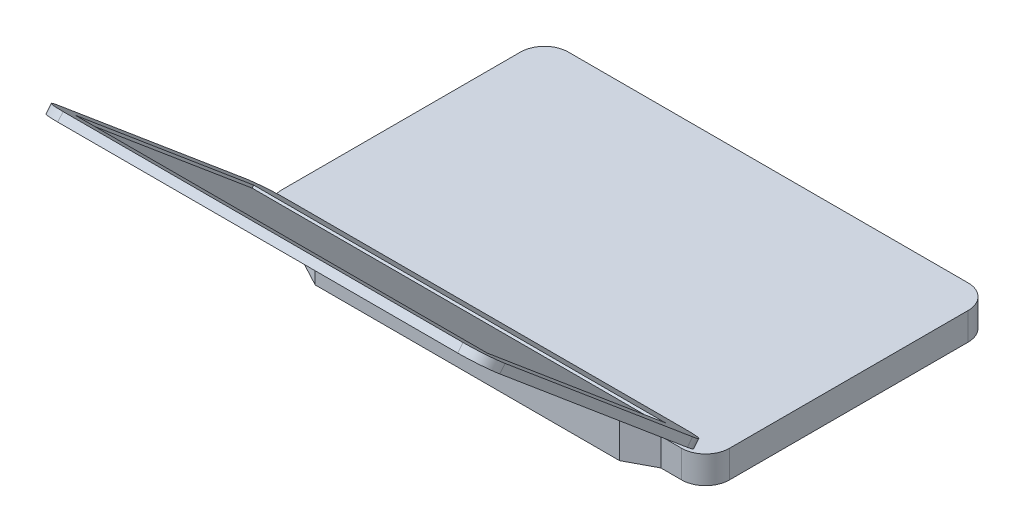
from build123d import *

# Parameters (mm, degrees)
SKETCH1_W           = 375
SKETCH1_H           = 240
BOSS_EXTRUDE1_DEPTH = 23
BOSS_EXTRUDE2_DEPTH = 34
CUT_EXTRUDE1_DEPTH  = 376
SKETCH5_W           = 375
SKETCH5_H           = 245
BOSS_EXTRUDE3_DEPTH = 7
SKETCH6_W           = 345
SKETCH6_H           = 195
CUT_EXTRUDE2_DEPTH  = 2
FILLET1_R           = 20


with BuildPart() as part:
    # Sketch1 → Boss-Extrude1 (new body)
    with BuildSketch(Plane(origin=(0, 0, 0), x_dir=(1, 0, 0), z_dir=(0, 1, 0))):
        Rectangle(SKETCH1_W, SKETCH1_H)
    extrude(amount=BOSS_EXTRUDE1_DEPTH)

    # Sketch3 → Boss-Extrude2 (add)
    with BuildSketch(Plane.XZ):
        Polygon((-150, 120), (-127.5, 132), (127.5, 132), (150, 120), align=None)
    extrude(amount=-BOSS_EXTRUDE2_DEPTH)

    # Sketch4 → Cut-Extrude1 (cut, through all)
    with BuildSketch(Plane.ZY.offset(187.5)):
        Polygon((120, 28.5), (126.554644759, 34), (120, 34), align=None)
    extrude(amount=-CUT_EXTRUDE1_DEPTH, mode=Mode.SUBTRACT)

    # Sketch5 → Boss-Extrude3 (add)
    with BuildSketch(Plane(origin=(0, -42.363978649, 35.54759886), x_dir=(-1, 0, 0), z_dir=(0, 0.766044443, -0.64278761))):
        with Locations((0, 232.74478005)):
            Rectangle(SKETCH5_W, SKETCH5_H)
    extrude(amount=BOSS_EXTRUDE3_DEPTH)

    # Sketch6 → Cut-Extrude2 (cut)
    with BuildSketch(Plane(origin=(0, -37.001667547, 31.048085592), x_dir=(1, 0, 0), z_dir=(0, 0.766044443, -0.64278761))):
        with Locations((0, -237.74478005)):
            Rectangle(SKETCH6_W, SKETCH6_H)
    extrude(amount=-CUT_EXTRUDE2_DEPTH, mode=Mode.SUBTRACT)

    # Fillet1
    fillet1_edges = [part.edges().sort_by_distance(p)[0] for p in [
        (187.5, 188.664119924, 305.43113193),
        (187.5, 31.181155551, 117.750243366),
        (-187.5, 31.181155551, 117.750243366),
        (-187.5, 188.664119924, 305.43113193),
        (-187.5, 11.5, -120),
        (187.5, 11.5, -120),
        (187.5, 11.5, 120),
        (-187.5, 11.5, 120),
    ]]
    fillet(fillet1_edges, radius=FILLET1_R)


solid = part.part
